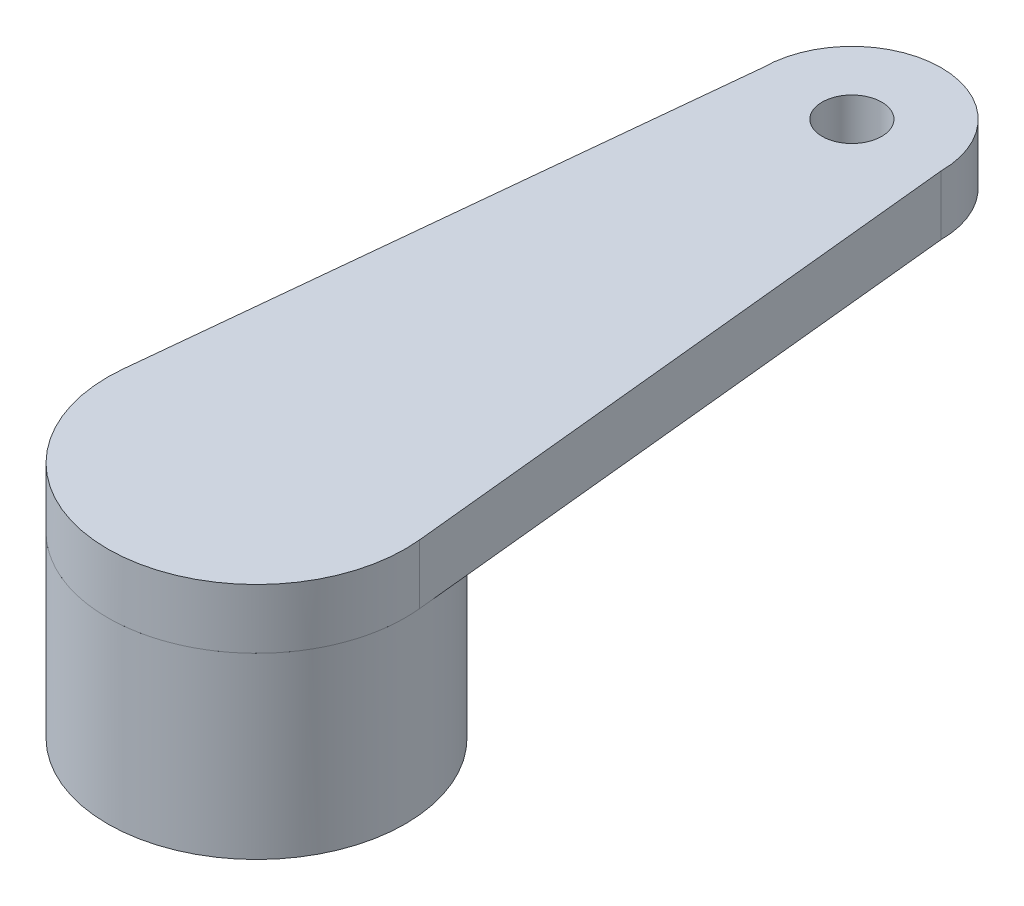
from build123d import *

# Parameters (mm, degrees)
SKETCH1_R           = 2.5
SKETCH1_R_2         = 1.5
BOSS_EXTRUDE1_DEPTH = 3
SKETCH3_R           = 0.5
BOSS_EXTRUDE2_DEPTH = 1


with BuildPart() as part:
    # Sketch1 → Boss-Extrude1 (new body)
    with BuildSketch(Plane(origin=(0, 0, 0), x_dir=(1, 0, 0), z_dir=(0, 1, 0))):
        Circle(SKETCH1_R)
        Circle(SKETCH1_R_2, mode=Mode.SUBTRACT)
    extrude(amount=BOSS_EXTRUDE1_DEPTH)

    # Sketch3 → Boss-Extrude2 (add)
    with BuildSketch(Plane(origin=(0, 3, 0), x_dir=(1, 0, 0), z_dir=(0, 1, 0))):
        with BuildLine():
            Line((-1.5, 10), (-2.487237034, 0.251894326))
            ThreePointArc((-2.487237034, 0.251894326), (0, -2.499959763), (2.487237034, 0.251894326))
            Line((2.487237034, 0.251894326), (1.5, 10))
            ThreePointArc((1.5, 10), (0, 11.5), (-1.5, 10))
        make_face()
        with Locations((0, 10)):
            Circle(SKETCH3_R, mode=Mode.SUBTRACT)
    extrude(amount=BOSS_EXTRUDE2_DEPTH)


solid = part.part
